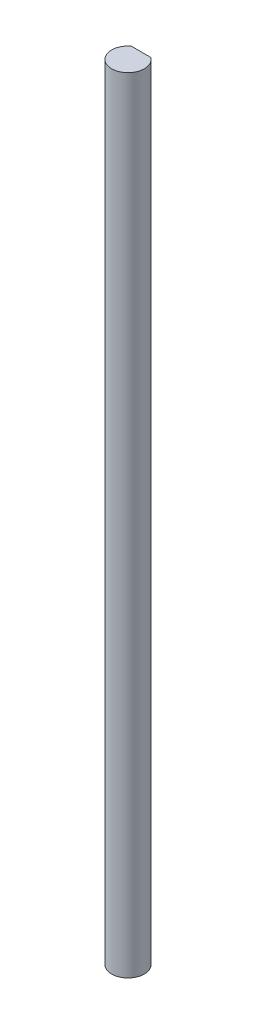
from build123d import *

# Parameters (mm, degrees)
BOSS_EXTRUDE1_DEPTH = 152.4


with BuildPart() as part:
    # Sketch1 → Boss-Extrude1 (new body)
    with BuildSketch(Plane(origin=(0, 0, 0), x_dir=(1, 0, 0), z_dir=(0, 1, 0))):
        with BuildLine():
            Line((-1.905, 2.54), (1.905, 2.54))
            ThreePointArc((1.905, 2.54), (0, -3.175), (-1.905, 2.54))
        make_face()
    extrude(amount=BOSS_EXTRUDE1_DEPTH)


solid = part.part
